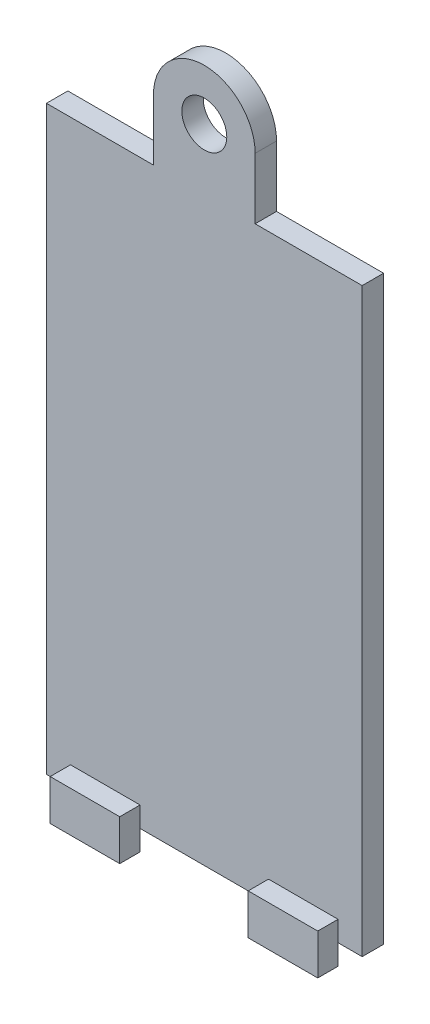
from build123d import *

# Parameters (mm, degrees)
SKETCH1_W           = 54.5
SKETCH1_H           = 29.5
BOSS_EXTRUDE1_DEPTH = 2
SKETCH2_W           = 6.5
SKETCH2_H           = 1.9
BOSS_EXTRUDE2_DEPTH = 1.9
SKETCH4_W           = 6.5
SKETCH4_H           = 1.9
BOSS_EXTRUDE3_DEPTH = 1.9
SKETCH5_R           = 2.1
BOSS_EXTRUDE4_DEPTH = 2
SKETCH6_W           = 15.900329316
SKETCH6_H           = 0.2
SKETCH6_W_2         = 14.215882728
CUT_EXTRUDE1_DEPTH  = 10


with BuildPart() as part:
    # Sketch1 → Boss-Extrude1 (new body)
    with BuildSketch(Plane(origin=(0, 0, 0), x_dir=(0, 1, 0), z_dir=(0, 0, 1))):
        Rectangle(SKETCH1_W, SKETCH1_H)
    extrude(amount=BOSS_EXTRUDE1_DEPTH)

    # Sketch2 → Boss-Extrude2 (add, symmetric)
    with BuildSketch(Plane.XZ.offset(27.25)):
        with Locations((-9.25, 2.95)):
            Rectangle(SKETCH2_W, SKETCH2_H)
    extrude(amount=BOSS_EXTRUDE2_DEPTH, both=True)

    # Sketch4 → Boss-Extrude3 (add, symmetric)
    with BuildSketch(Plane.XZ.offset(27.25)):
        with Locations((9.25, 2.95)):
            Rectangle(SKETCH4_W, SKETCH4_H)
    extrude(amount=BOSS_EXTRUDE3_DEPTH, both=True)

    # Sketch5 → Boss-Extrude4 (add)
    with BuildSketch(Plane.XY.offset(2)):
        with BuildLine():
            Line((-4.75, 32.75), (-4.75, 27.25))
            Line((-4.75, 27.25), (4.75, 27.25))
            Line((4.75, 27.25), (4.75, 32.75))
            ThreePointArc((4.75, 32.75), (0, 37.5), (-4.75, 32.75))
        make_face()
        with Locations((0, 32.75)):
            Circle(SKETCH5_R, mode=Mode.SUBTRACT)
    extrude(amount=-BOSS_EXTRUDE4_DEPTH)

    # Sketch6 → Cut-Extrude1 (cut)
    with BuildSketch(Plane.XY.offset(2)):
        with Locations((-12.700164658, 27.15)):
            Rectangle(SKETCH6_W, SKETCH6_H)
        with Locations((11.857941364, 27.15)):
            Rectangle(SKETCH6_W_2, SKETCH6_H)
    extrude(amount=-CUT_EXTRUDE1_DEPTH, mode=Mode.SUBTRACT)


solid = part.part
